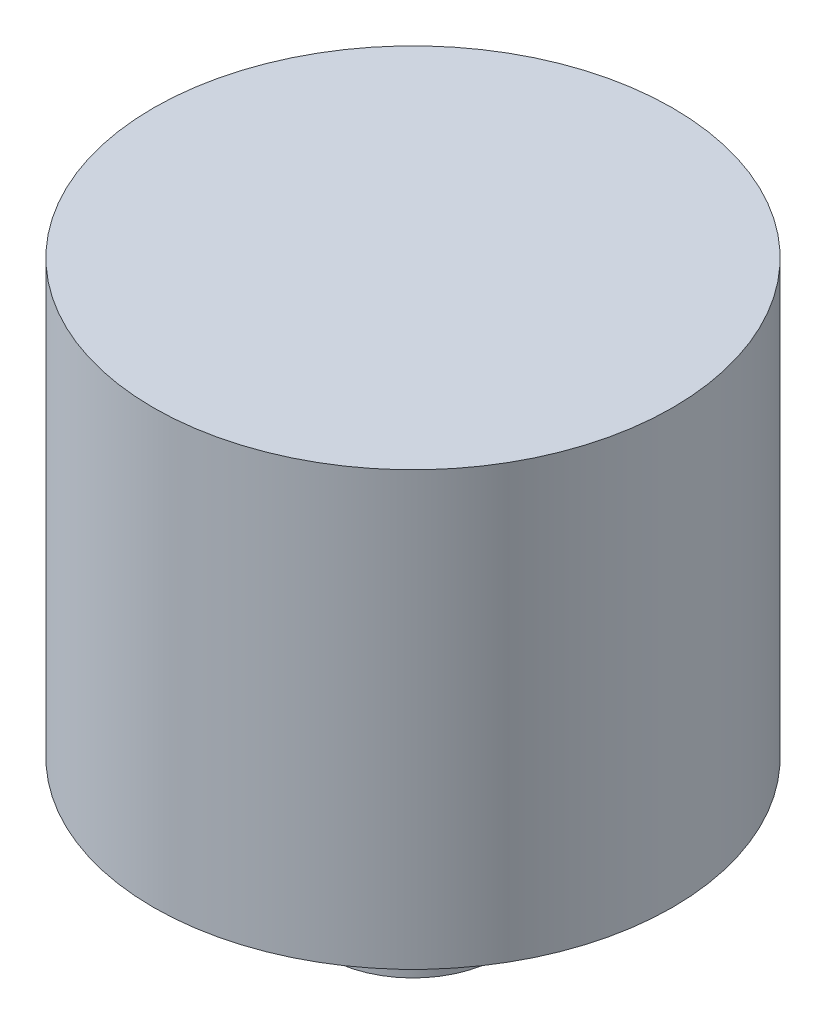
from build123d import *


with BuildPart() as part:
    # Sketch1 → Revolve1 (revolve)
    with BuildSketch(Plane.XY):
        Polygon((0, 0), (-2, 0), (-2, 3), (-6, 3), (-6, 13), (0, 13), align=None)
    revolve(axis=Axis((0, 13, 0), (0, -1, 0)))


solid = part.part
